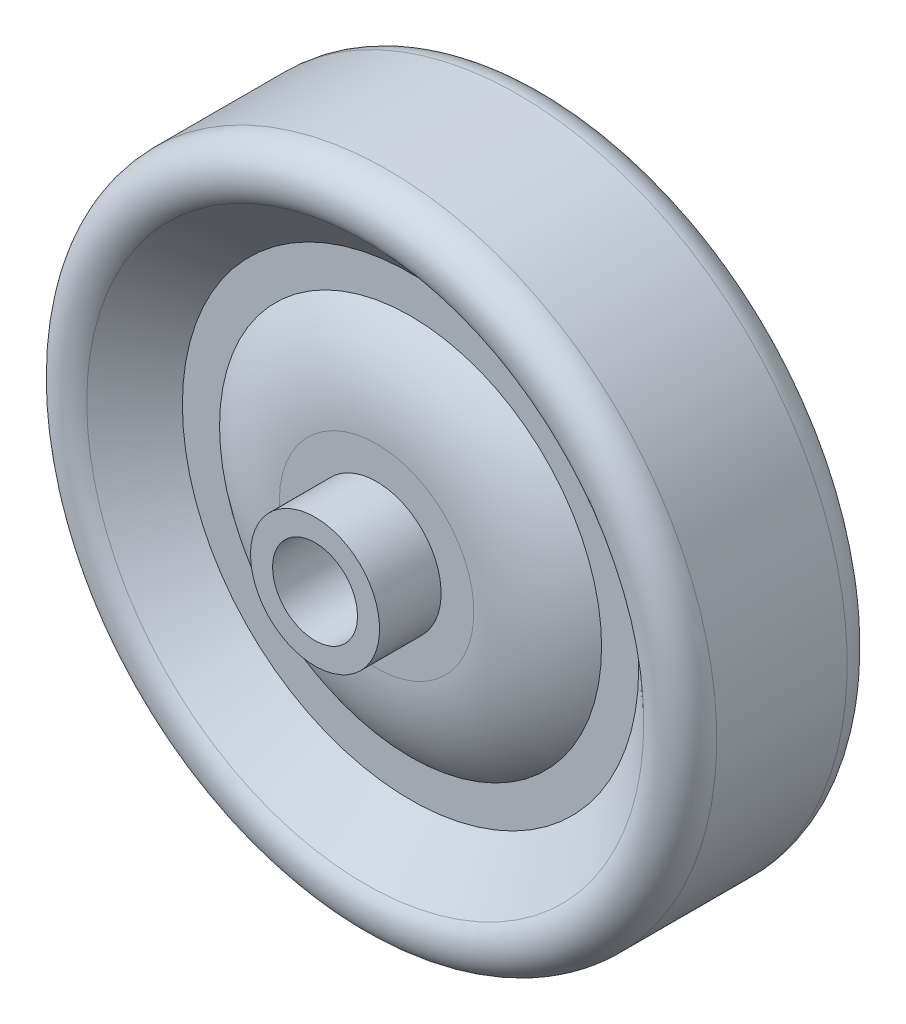
from build123d import *


with BuildPart() as part:
    # Sketch1 → Revolve1 (revolve)
    with BuildSketch(Plane(origin=(0, 0, 0), x_dir=(0, 0, -1), z_dir=(1, 0, 0)), mode=Mode.PRIVATE) as revolve1_sk:
        with BuildLine():
            Line((0, 24.60625), (4.8815625, 24.60625))
            ThreePointArc((4.8815625, 24.60625), (6.948032483, 23.264493972), (6.563159633, 20.83087931))
            Line((6.563159633, 20.83087931), (3.175, 17.065625))
            Line((3.175, 17.065625), (3.175, 14.2875))
            ThreePointArc((3.175, 14.2875), (5.060465212, 11.001230365), (5.715, 7.269457141))
            Line((5.715, 7.269457141), (5.715, 4.826))
            Line((5.715, 4.826), (10.31875, 4.826))
            Line((10.31875, 4.826), (10.31875, 3.175))
            Line((10.31875, 3.175), (0, 3.175))
            Line((0, 3.175), (0, 24.60625))
        make_face()
    revolve(revolve1_sk.sketch.rotate(Axis((0, 0, -10.31875), (0, 0, 1)), 90), axis=Axis((0, 0, -10.31875), (0, 0, 1)))

    # Mirror1: part across plane


with BuildPart() as part_1:
    add(part.part)
    add(part.part.mirror(Plane.XY))


solid = part_1.part
